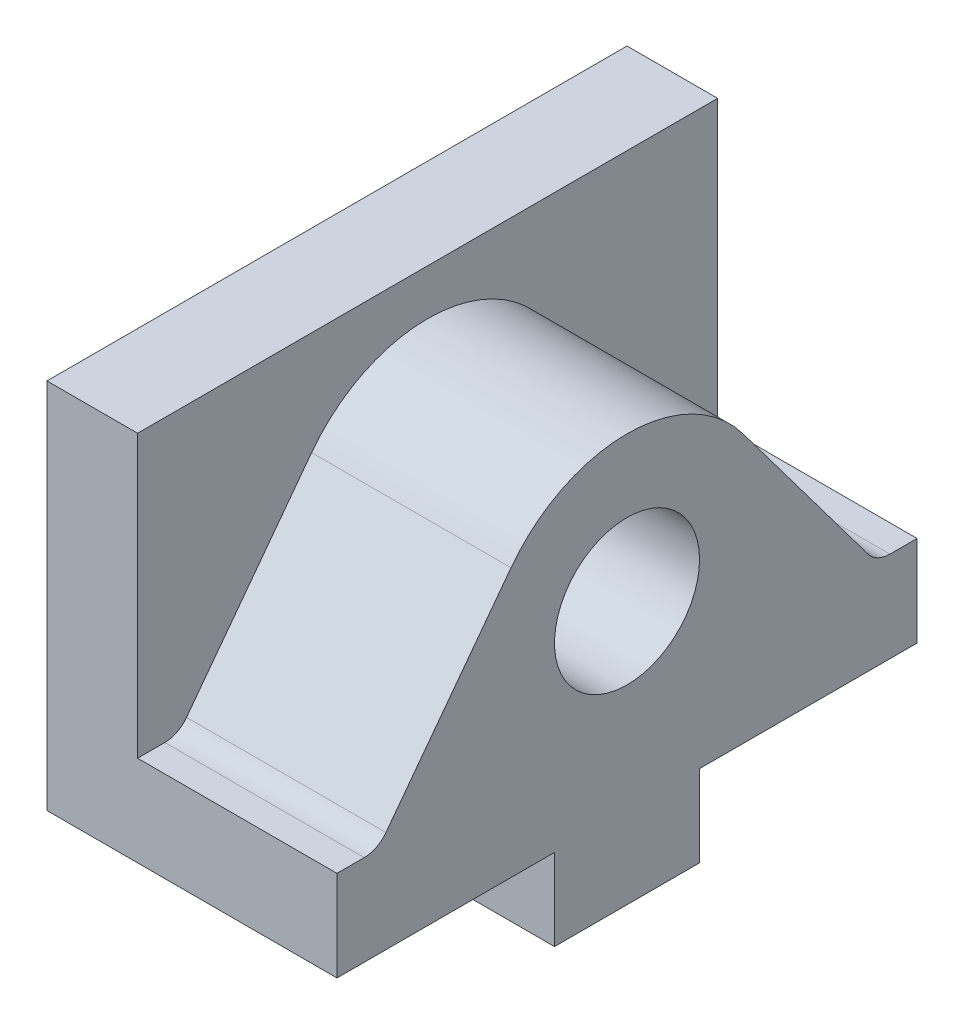
from build123d import *

# Parameters (mm, degrees)
SKETCH1_R           = 8
BOSS_EXTRUDE2_DEPTH = 22
SKETCH2_R           = 8
SKETCH2_W           = 16
SKETCH2_H           = 9
BOSS_EXTRUDE4_DEPTH = 10


with BuildPart() as part:
    # Sketch1 → Boss-Extrude2 (new body)
    with BuildSketch(Plane(origin=(0, 0, 0), x_dir=(0, 0, -1), z_dir=(1, 0, 0))):
        with BuildLine():
            Line((32, -8), (29, -8))
            ThreePointArc((29, -8), (27.658359214, -7.683281573), (26.6, -6.8))
            Line((26.6, -6.8), (12.8, 11.6))
            ThreePointArc((12.8, 11.6), (0, 18), (-12.8, 11.6))
            Line((-12.8, 11.6), (-26.6, -6.8))
            ThreePointArc((-26.6, -6.8), (-27.658359214, -7.683281573), (-29, -8))
            Line((-29, -8), (-32, -8))
            Line((-32, -8), (-32, -18))
            Line((-32, -18), (-8, -18))
            Line((-8, -18), (-8, -27))
            Line((-8, -27), (8, -27))
            Line((8, -27), (8, -18))
            Line((8, -18), (32, -18))
            Line((32, -18), (32, -8))
        make_face()
        with Locations((0, 2)):
            Circle(SKETCH1_R, mode=Mode.SUBTRACT)
    extrude(amount=BOSS_EXTRUDE2_DEPTH)

    # Sketch2 → Boss-Extrude4 (add)
    with BuildSketch(Plane.ZY):
        with BuildLine():
            Line((-32, 23.051846753), (-32, -8))
            Line((-32, -8), (-29, -8))
            ThreePointArc((-29, -8), (-27.658359214, -7.683281573), (-26.6, -6.8))
            Line((-26.6, -6.8), (-12.8, 11.6))
            ThreePointArc((-12.8, 11.6), (0, 18), (12.8, 11.6))
            Line((12.8, 11.6), (26.6, -6.8))
            ThreePointArc((26.6, -6.8), (27.658359214, -7.683281573), (29, -8))
            Line((29, -8), (32, -8))
            Line((32, -8), (32, 23.051846753))
            Line((32, 23.051846753), (-32, 23.051846753))
        make_face()
        with BuildLine():
            Line((-32, -18), (-8, -18))
            Line((-8, -18), (8, -18))
            Line((8, -18), (32, -18))
            Line((32, -18), (32, -8))
            Line((32, -8), (29, -8))
            ThreePointArc((29, -8), (27.658359214, -7.683281573), (26.6, -6.8))
            Line((26.6, -6.8), (12.8, 11.6))
            ThreePointArc((12.8, 11.6), (0, 18), (-12.8, 11.6))
            Line((-12.8, 11.6), (-26.6, -6.8))
            ThreePointArc((-26.6, -6.8), (-27.658359214, -7.683281573), (-29, -8))
            Line((-29, -8), (-32, -8))
            Line((-32, -8), (-32, -18))
        make_face()
        with Locations((0, 2)):
            Circle(SKETCH2_R, mode=Mode.SUBTRACT)
        with Locations((0, -22.5)):
            Rectangle(SKETCH2_W, SKETCH2_H)
        with Locations((0, 2)):
            Circle(SKETCH2_R)
    extrude(amount=BOSS_EXTRUDE4_DEPTH)


solid = part.part
